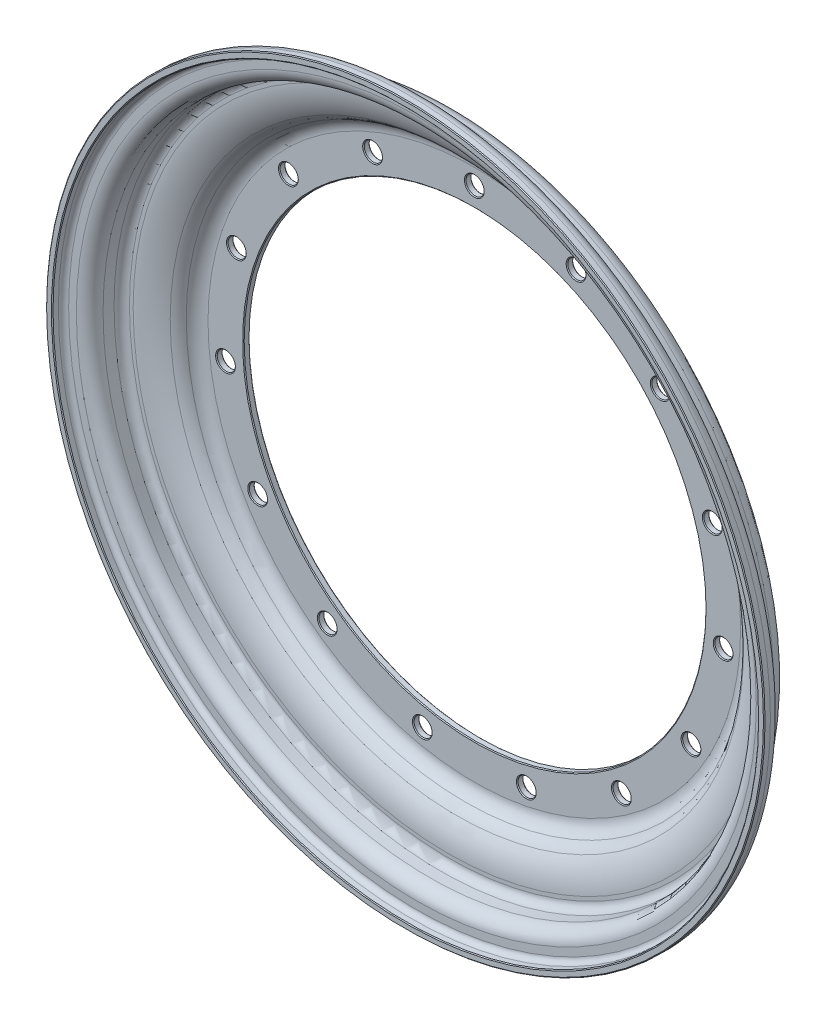
from build123d import *

# Parameters (mm, degrees)
SKETCH2_R                   = 4.49834
MOUNTING_HOLE_DEPTH         = 4.175
MOUNTING_HOLE_PATTERN_COUNT = 15
EDGE_CHAMFER_SIZE           = 0.39624


with BuildPart() as part:
    # Sketch1 → Inner Rim (revolve)
    with BuildSketch(Plane(origin=(0, 0, 0), x_dir=(0, 0, -1), z_dir=(1, 0, 0))):
        with BuildLine():
            Line((0, 114.3), (0, 131.81076))
            ThreePointArc((0, 131.81076), (-1.708204623, 137.450036516), (-6.25856, 141.19352))
            ThreePointArc((-6.25856, 141.19352), (-7.886461195, 142.179734532), (-9.14908, 143.60398))
            ThreePointArc((-9.14908, 143.60398), (-11.886505839, 149.554103055), (-12.824644135, 156.036183055))
            Line((-12.824644135, 156.036183055), (-12.824644135, 157.862443055))
            ThreePointArc((-12.824644135, 157.862443055), (-14.870457346, 162.801473055), (-19.809487346, 164.847286266))
            Line((-19.809487346, 164.847286266), (-25.270487346, 164.847286266))
            ThreePointArc((-25.270487346, 164.847286266), (-27.694917346, 165.851518053), (-28.699149133, 168.275948053))
            Line((-28.699149133, 168.275948053), (-28.699149133, 172.085948053))
            ThreePointArc((-28.699149133, 172.085948053), (-30.373044128, 176.127088053), (-34.414184128, 177.800983048))
            Line((-34.414184128, 177.800983048), (-37.462184128, 177.800983048))
            Line((-37.462184128, 177.800983048), (-37.462184128, 174.625983048))
            Line((-37.462184128, 174.625983048), (-34.414184128, 174.625983048))
            ThreePointArc((-34.414184128, 174.625983048), (-32.618108159, 173.882024022), (-31.874149133, 172.085948053))
            Line((-31.874149133, 172.085948053), (-31.874149133, 168.275948053))
            ThreePointArc((-31.874149133, 168.275948053), (-29.939981376, 163.606454022), (-25.270487346, 161.672286266))
            Line((-25.270487346, 161.672286266), (-19.809487346, 161.672286266))
            ThreePointArc((-19.809487346, 161.672286266), (-17.115521376, 160.556409025), (-15.999644135, 157.862443055))
            Line((-15.999644135, 157.862443055), (-15.999644135, 156.036183055))
            ThreePointArc((-15.999644135, 156.036183055), (-14.931226414, 148.653935506), (-11.813653785, 141.877517854))
            ThreePointArc((-11.813653785, 141.877517854), (-9.919889574, 139.741334641), (-7.478249224, 138.26214094))
            ThreePointArc((-7.478249224, 138.26214094), (-4.349524206, 135.68820342), (-3.175, 131.81076))
            Line((-3.175, 131.81076), (-3.175, 114.3))
            Line((-3.175, 114.3), (0, 114.3))
        make_face()
    revolve(axis=Axis((0, 0, -1.873109206), (0, 0, 1)))

    # Sketch2 → Mounting Hole (cut, through all)
    with BuildSketch(Plane.XY.offset(3.175)):
        with Locations((0, 123.825)):
            Circle(SKETCH2_R)
    mounting_hole = extrude(amount=-MOUNTING_HOLE_DEPTH, mode=Mode.SUBTRACT)

    # Mounting Hole Pattern: Mounting Hole ×15 about axis
    mounting_hole_pattern_axis = Axis((0, 0, 0), (0, 0, 1))
    for i in range(1, MOUNTING_HOLE_PATTERN_COUNT):
        add(mounting_hole.rotate(mounting_hole_pattern_axis, i * 360 / MOUNTING_HOLE_PATTERN_COUNT), mode=Mode.SUBTRACT)

    # Edge Chamfer
    edge_chamfer_edges = [part.edges().sort_by_distance(p)[0] for p in [
        (116.374509624, 42.542204898, 0),
        (116.374509624, 42.542204898, 3.175),
        (89.009931043, 86.198015427, 0),
        (89.009931043, 86.198015427, 3.175),
        (46.254726755, 114.949406004, 0),
        (46.254726755, 114.949406004, 3.175),
        (0, -114.3, 3.175),
        (0, -174.625983048, 37.462184128),
        (0, -177.800983048, 37.462184128),
        (0, -114.3, 0),
        (-4.49834, 123.825, 0),
        (-4.49834, 123.825, 3.175),
        (-54.473602903, 111.290126582, 0),
        (-54.473602903, 111.290126582, 3.175),
        (-95.029884987, 79.512179238, 0),
        (-95.029884987, 79.512179238, 3.175),
        (-119.154636637, 33.985853759, 0),
        (-119.154636637, 33.985853759, 3.175),
        (-122.676469127, -17.416934587, 0),
        (-122.676469127, -17.416934587, 3.175),
        (-104.986425624, -65.808176715, 0),
        (-104.986425624, -65.808176715, 3.175),
        (-69.143275359, -102.82058724, 0),
        (-69.143275359, -102.82058724, 3.175),
        (-21.344624637, -122.054384136, 0),
        (-21.344624637, -122.054384136, 3.175),
        (30.144705594, -120.183869186, 0),
        (30.144705594, -120.183869186, 3.175),
        (76.421742372, -97.532471417, 0),
        (76.421742372, -97.532471417, 3.175),
        (109.484765624, -58.016823285, 0),
        (109.484765624, -58.016823285, 3.175),
        (123.616878261, -8.469539341, 0),
        (123.616878261, -8.469539341, 3.175),
    ]]
    chamfer(edge_chamfer_edges, length=EDGE_CHAMFER_SIZE)


solid = part.part
